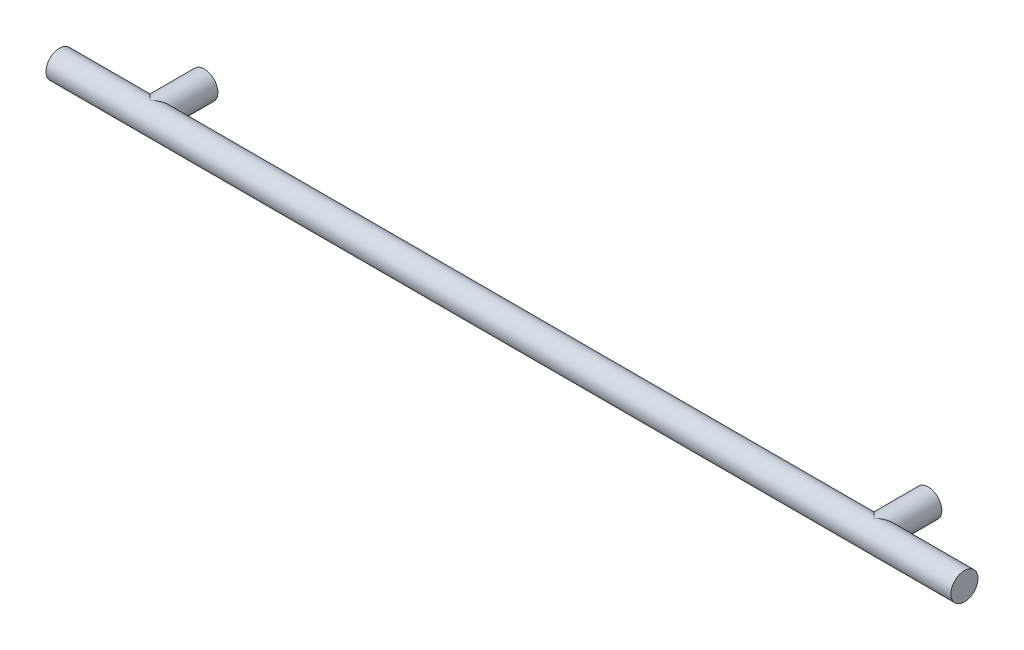
from build123d import *

# Parameters (mm, degrees)
SKETCH2_R           = 4.7625
BOSS_EXTRUDE1_DEPTH = 158.75
BOSS_EXTRUDE2_REACH = 25.812
SKETCH1_R           = 4.7625


with BuildPart() as part:
    # Sketch2 → Boss-Extrude1 (new body, symmetric)
    with BuildSketch(Plane(origin=(0, 0, 0), x_dir=(0, 0, -1), z_dir=(1, 0, 0))):
        with Locations((-19.05, 0)):
            Circle(SKETCH2_R)
    extrude(amount=BOSS_EXTRUDE1_DEPTH, both=True)

    # Sketch1 → Boss-Extrude2 (add, up to next)
    with BuildSketch(Plane.XY, mode=Mode.PRIVATE) as boss_extrude2_sk1:
        with Locations((-127, 0)):
            Circle(SKETCH1_R)
    boss_extrude2_tool1 = extrude(boss_extrude2_sk1.sketch, amount=BOSS_EXTRUDE2_REACH, mode=Mode.PRIVATE) - part.part
    add(boss_extrude2_tool1.solids().sort_by_distance((-127, 0, 0))[0])
    # Sketch1 → Boss-Extrude2 (add, up to next)
    with BuildSketch(Plane.XY, mode=Mode.PRIVATE) as boss_extrude2_sk2:
        with Locations((127, 0)):
            Circle(SKETCH1_R)
    boss_extrude2_tool2 = extrude(boss_extrude2_sk2.sketch, amount=BOSS_EXTRUDE2_REACH, mode=Mode.PRIVATE) - part.part
    add(boss_extrude2_tool2.solids().sort_by_distance((127, 0, 0))[0])


solid = part.part
